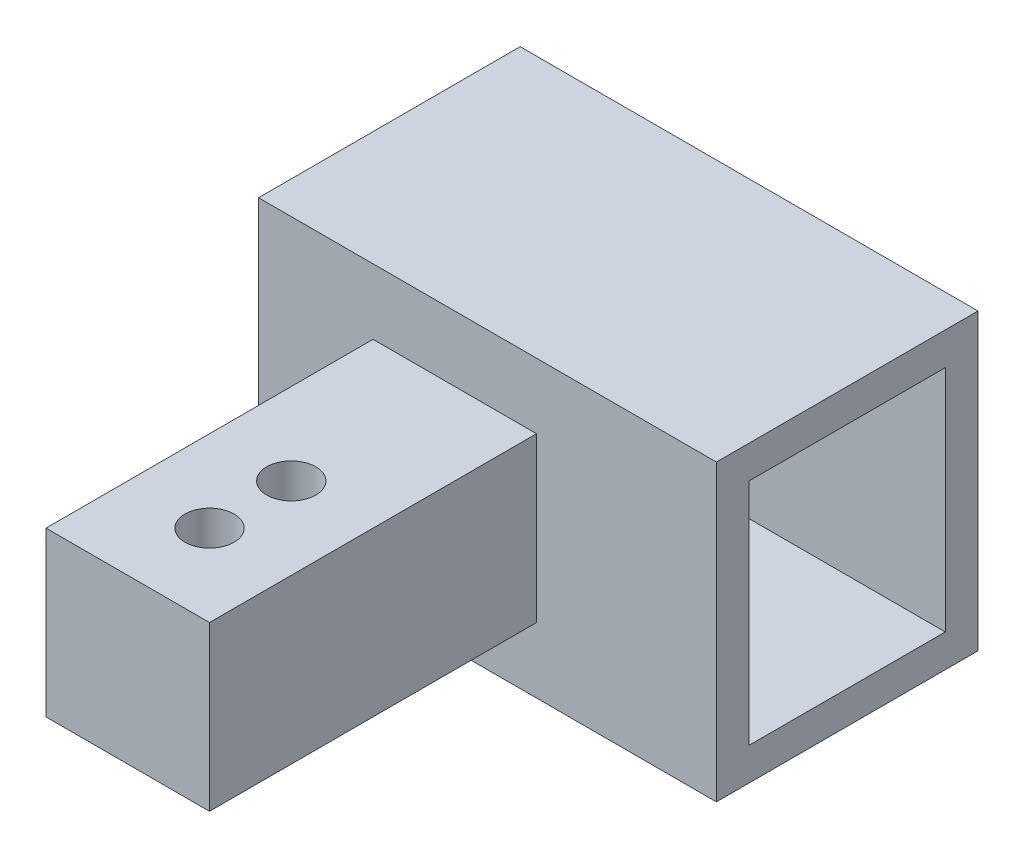
from build123d import *

# Parameters (mm, degrees)
SKETCH1_W           = 28
SKETCH1_H           = 16
BOSS_EXTRUDE1_DEPTH = 18
SKETCH3_W           = 10
SKETCH3_H           = 10
BOSS_EXTRUDE2_DEPTH = 20
SKETCH4_W           = 12
SKETCH4_H           = 14
CUT_EXTRUDE1_DEPTH  = 25
SKETCH5_R           = 1.5
CUT_EXTRUDE2_DEPTH  = 25
SKETCH4_2_W         = 12
SKETCH4_2_H         = 14
CUT_EXTRUDE3_DEPTH  = 26


with BuildPart() as part:
    # Sketch1 → Boss-Extrude1 (new body)
    with BuildSketch(Plane(origin=(0, 0, 0), x_dir=(1, 0, 0), z_dir=(0, 1, 0))):
        with Locations((0.461538462, -2.646153846)):
            Rectangle(SKETCH1_W, SKETCH1_H)
    extrude(amount=BOSS_EXTRUDE1_DEPTH)

    # Sketch3 → Boss-Extrude2 (add)
    with BuildSketch(Plane.XY.offset(10.646153846)):
        with Locations((-1.538461538, 9)):
            Rectangle(SKETCH3_W, SKETCH3_H)
    extrude(amount=BOSS_EXTRUDE2_DEPTH)

    # Sketch4 → Cut-Extrude1 (cut)
    with BuildSketch(Plane(origin=(14.461538462, 0, 0), x_dir=(0, 0, -1), z_dir=(1, 0, 0))):
        with Locations((-2.646153846, 9)):
            Rectangle(SKETCH4_W, SKETCH4_H)
    extrude(amount=-CUT_EXTRUDE1_DEPTH, mode=Mode.SUBTRACT)

    # Sketch5 → Cut-Extrude2 (cut)
    with BuildSketch(Plane(origin=(0, 14, 0), x_dir=(1, 0, 0), z_dir=(0, 1, 0))):
        with Locations((-1.538461538, -20.646153846)):
            Circle(SKETCH5_R)
        with Locations((-1.538461538, -25.646153846)):
            Circle(SKETCH5_R)
    extrude(amount=-CUT_EXTRUDE2_DEPTH, mode=Mode.SUBTRACT)

    # Sketch4_2 → Cut-Extrude3 (cut)
    with BuildSketch(Plane(origin=(14.461538462, 0, 0), x_dir=(0, 0, -1), z_dir=(1, 0, 0))):
        with Locations((-2.646153846, 9)):
            Rectangle(SKETCH4_2_W, SKETCH4_2_H)
    extrude(amount=-CUT_EXTRUDE3_DEPTH, mode=Mode.SUBTRACT)


solid = part.part
